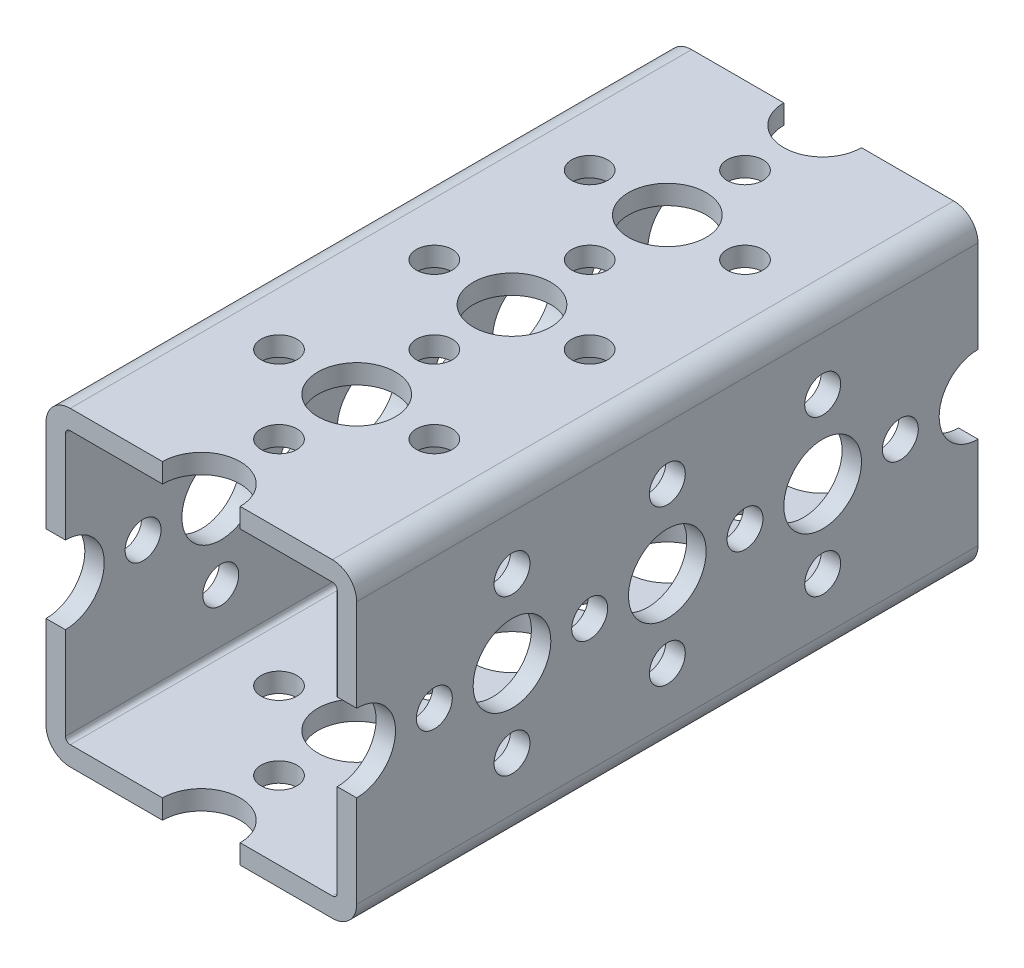
from build123d import *

# Parameters (mm, degrees)
BOSS_EXTRUDE1_DEPTH = 32
SKETCH2_R           = 4
SKETCH2_R_2         = 1.85
CUT_EXTRUDE1_DEPTH  = 33
CIRPATTERN1_COUNT   = 2
CIRPATTERN1_ANGLE   = 90


with BuildPart() as part:
    # Sketch1 → Boss-Extrude1 (new body, symmetric)
    with BuildSketch(Plane.XY):
        with BuildLine():
            Line((-13.5, 16), (13.5, 16))
            ThreePointArc((13.5, 16), (15.267766953, 15.267766953), (16, 13.5))
            Line((16, 13.5), (16, -13.5))
            ThreePointArc((16, -13.5), (15.267766953, -15.267766953), (13.5, -16))
            Line((13.5, -16), (-13.5, -16))
            ThreePointArc((-13.5, -16), (-15.267766953, -15.267766953), (-16, -13.5))
            Line((-16, -13.5), (-16, 13.5))
            ThreePointArc((-16, 13.5), (-15.267766953, 15.267766953), (-13.5, 16))
        make_face()
        with BuildLine():
            Line((-13.5, 14), (13.5, 14))
            ThreePointArc((13.5, 14), (13.853553391, 13.853553391), (14, 13.5))
            Line((14, 13.5), (14, -13.5))
            ThreePointArc((14, -13.5), (13.853553391, -13.853553391), (13.5, -14))
            Line((13.5, -14), (-13.5, -14))
            ThreePointArc((-13.5, -14), (-13.853553391, -13.853553391), (-14, -13.5))
            Line((-14, -13.5), (-14, 13.5))
            ThreePointArc((-14, 13.5), (-13.853553391, 13.853553391), (-13.5, 14))
        make_face(mode=Mode.SUBTRACT)
    extrude(amount=BOSS_EXTRUDE1_DEPTH, both=True)

    # Sketch2 → Cut-Extrude1 (cut, through all)
    with BuildSketch(Plane(origin=(16, 0, 0), x_dir=(0, 0, -1), z_dir=(1, 0, 0))):
        Circle(SKETCH2_R)
        with Locations((16, 0)):
            Circle(SKETCH2_R)
        with Locations((32, 0)):
            Circle(SKETCH2_R)
        with Locations((-16, 0)):
            Circle(SKETCH2_R)
        with Locations((-32, 0)):
            Circle(SKETCH2_R)
        with Locations((24, 0)):
            Circle(SKETCH2_R_2)
        with Locations((16, 8)):
            Circle(SKETCH2_R_2)
        with Locations((16, -8)):
            Circle(SKETCH2_R_2)
        with Locations((8, 0)):
            Circle(SKETCH2_R_2)
        with Locations((-8, 0)):
            Circle(SKETCH2_R_2)
        with Locations((-24, 0)):
            Circle(SKETCH2_R_2)
        with Locations((-16, -8)):
            Circle(SKETCH2_R_2)
        with Locations((-16, 8)):
            Circle(SKETCH2_R_2)
        with Locations((0, 8)):
            Circle(SKETCH2_R_2)
        with Locations((0, -8)):
            Circle(SKETCH2_R_2)
    cut_extrude1 = extrude(amount=-CUT_EXTRUDE1_DEPTH, mode=Mode.SUBTRACT)

    # CirPattern1: Cut-Extrude1 ×2 about axis
    cirpattern1_axis = Axis((0, 0, -17.6), (0, 0, 1))
    for i in range(1, CIRPATTERN1_COUNT):
        add(cut_extrude1.rotate(cirpattern1_axis, i * CIRPATTERN1_ANGLE / (CIRPATTERN1_COUNT - 1)), mode=Mode.SUBTRACT)


solid = part.part
